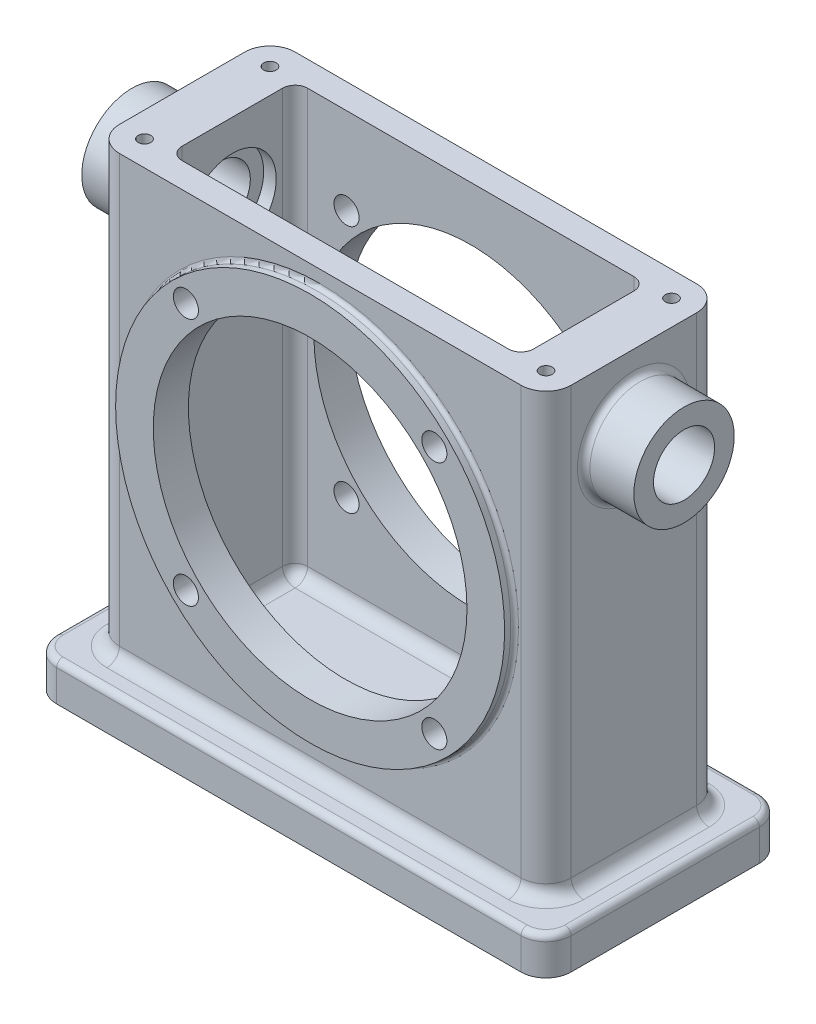
from build123d import *

# Parameters (mm, degrees)
SKETCH1_W           = 130.175
SKETCH1_H           = 60.325
BASE_EXTRUDE_DEPTH  = 9.525
SKETCH2_W           = 114.3
SKETCH2_H           = 44.45
BOSS_EXTRUDE1_DEPTH = 111.125
FILLET1_R           = 6.35
FILLET2_R           = 1.5875
FILLET3_R           = 3.175
CUT_EXTRUDE1_DEPTH  = 107.95
FILLET4_R           = 3.175
SKETCH4_R           = 49.2125
BOSS_EXTRUDE2_DEPTH = 2.54
SKETCH5_R           = 39.6875
CUT_EXTRUDE2_DEPTH  = 55.9275
FILLET5_R           = 0.9906
SKETCH6_R           = 12.7
BOSS_EXTRUDE3_DEPTH = 12.7
SKETCH7_R           = 7.7343
CUT_EXTRUDE3_DEPTH  = 26.4
SKETCH8_R           = 11.1125
CUT_EXTRUDE4_DEPTH  = 3.175
FILLET6_R           = 1.5875
SKETCH9_R           = 3.175
CUT_EXTRUDE5_DEPTH  = 55.9275
CIRPATTERN1_COUNT   = 4
SKETCH10_R          = 1.5875
CUT_EXTRUDE6_DEPTH  = 19.05


with BuildPart() as part:
    # Sketch1 → Base-Extrude (new body)
    with BuildSketch(Plane(origin=(0, 0, 0), x_dir=(1, 0, 0), z_dir=(0, 1, 0))):
        Rectangle(SKETCH1_W, SKETCH1_H)
    extrude(amount=BASE_EXTRUDE_DEPTH)

    # Sketch2 → Boss-Extrude1 (add)
    with BuildSketch(Plane(origin=(0, 9.525, 0), x_dir=(-1, 0, 0), z_dir=(0, 1, 0))):
        Rectangle(SKETCH2_W, SKETCH2_H)
    extrude(amount=BOSS_EXTRUDE1_DEPTH)

    # Fillet1
    fillet1_edges = [part.edges().sort_by_distance(p)[0] for p in [
        (-57.15, 65.0875, -22.225),
        (-57.15, 65.0875, 22.225),
        (57.15, 65.0875, 22.225),
        (57.15, 65.0875, -22.225),
        (-65.0875, 4.7625, -30.1625),
        (65.0875, 4.7625, -30.1625),
        (65.0875, 4.7625, 30.1625),
        (-65.0875, 4.7625, 30.1625),
    ]]
    fillet(fillet1_edges, radius=FILLET1_R)

    # Fillet2
    fillet2_edges = [part.edges().sort_by_distance(p)[0] for p in [
        (0, 9.525, 30.1625),
        (-65.0875, 9.525, 0),
        (65.0875, 9.525, 0),
        (0, 9.525, -30.1625),
        (-63.227628061, 9.525, -28.302628061),
        (63.227628061, 9.525, 28.302628061),
        (63.227628061, 9.525, -28.302628061),
        (-63.227628061, 9.525, 28.302628061),
    ]]
    fillet(fillet2_edges, radius=FILLET2_R)

    # Fillet3
    fillet3_edges = [part.edges().sort_by_distance(p)[0] for p in [
        (-57.15, 9.525, 0),
        (0, 9.525, -22.225),
        (57.15, 9.525, 0),
        (0, 9.525, 22.225),
        (-55.290128061, 9.525, 20.365128061),
        (-55.290128061, 9.525, -20.365128061),
        (55.290128061, 9.525, 20.365128061),
        (55.290128061, 9.525, -20.365128061),
    ]]
    fillet(fillet3_edges, radius=FILLET3_R)

    # Sketch3 → Cut-Extrude1 (cut)
    with BuildSketch(Plane(origin=(0, 120.65, 0), x_dir=(-1, 0, 0), z_dir=(0, 1, 0))):
        with BuildLine():
            Line((41.275, 15.875), (-41.275, 15.875))
            ThreePointArc((-41.275, 15.875), (-43.52006403, 14.94506403), (-44.45, 12.7))
            Line((-44.45, 12.7), (-44.45, -12.7))
            ThreePointArc((-44.45, -12.7), (-43.52006403, -14.94506403), (-41.275, -15.875))
            Line((-41.275, -15.875), (41.275, -15.875))
            ThreePointArc((41.275, -15.875), (43.52006403, -14.94506403), (44.45, -12.7))
            Line((44.45, -12.7), (44.45, 12.7))
            ThreePointArc((44.45, 12.7), (43.52006403, 14.94506403), (41.275, 15.875))
        make_face()
    extrude(amount=-CUT_EXTRUDE1_DEPTH, mode=Mode.SUBTRACT)

    # Fillet4
    fillet4_edges = [part.edges().sort_by_distance(p)[0] for p in [
        (0, 12.7, 15.875),
        (-44.45, 12.7, 0),
        (0, 12.7, -15.875),
        (44.45, 12.7, 0),
    ]]
    fillet(fillet4_edges, radius=FILLET4_R)

    # Sketch4 → Boss-Extrude2 (add)
    with BuildSketch(Plane.XY.offset(22.225)):
        with Locations((0, 67.31)):
            Circle(SKETCH4_R)
    boss_extrude2 = extrude(amount=BOSS_EXTRUDE2_DEPTH)

    # Mirror1: Boss-Extrude2 across plane
    add(boss_extrude2.mirror(Plane.XY))

    # Sketch5 → Cut-Extrude2 (cut, through all)
    with BuildSketch(Plane.XY.offset(24.765)):
        with Locations((0, 67.31)):
            Circle(SKETCH5_R)
    extrude(amount=-CUT_EXTRUDE2_DEPTH, mode=Mode.SUBTRACT)

    # Fillet5
    fillet5_edges = [part.edges().sort_by_distance(p)[0] for p in [
        (-49.2125, 67.31, 22.225),
        (-49.2125, 67.31, -22.225),
    ]]
    fillet(fillet5_edges, radius=FILLET5_R)

    # Sketch6 → Boss-Extrude3 (add)
    with BuildSketch(Plane(origin=(57.15, 0, 0), x_dir=(0, 0, -1), z_dir=(1, 0, 0))):
        with Locations((0, 101.6)):
            Circle(SKETCH6_R)
    boss_extrude3 = extrude(amount=BOSS_EXTRUDE3_DEPTH)

    # Sketch7 → Cut-Extrude3 (cut, through all)
    with BuildSketch(Plane.ZY.offset(-44.45)):
        with Locations((0, 101.6)):
            Circle(SKETCH7_R)
    cut_extrude3 = extrude(amount=-CUT_EXTRUDE3_DEPTH, mode=Mode.SUBTRACT)

    # Sketch8 → Cut-Extrude4 (cut)
    with BuildSketch(Plane.ZY.offset(-44.45)):
        with Locations((0, 101.6)):
            Circle(SKETCH8_R)
    cut_extrude4 = extrude(amount=-CUT_EXTRUDE4_DEPTH, mode=Mode.SUBTRACT)

    # Mirror3: Boss-Extrude3, Cut-Extrude3, Cut-Extrude4 across plane
    add(boss_extrude3.mirror(Plane(origin=(0, 0, 0), x_dir=(0, 0, 1), z_dir=(1, 0, 0))))
    add(cut_extrude3.mirror(Plane(origin=(0, 0, 0), x_dir=(0, 0, 1), z_dir=(1, 0, 0))), mode=Mode.SUBTRACT)
    add(cut_extrude4.mirror(Plane(origin=(0, 0, 0), x_dir=(0, 0, 1), z_dir=(1, 0, 0))), mode=Mode.SUBTRACT)

    # Fillet6
    fillet6_edges = [part.edges().sort_by_distance(p)[0] for p in [
        (57.15, 101.6, 12.7),
        (-57.15, 101.6, 12.7),
    ]]
    fillet(fillet6_edges, radius=FILLET6_R)

    # Sketch9 → Cut-Extrude5 (cut, through all)
    with BuildSketch(Plane.XY.offset(24.765)):
        with Locations((31.430896424, 98.740896424)):
            Circle(SKETCH9_R)
    cut_extrude5 = extrude(amount=-CUT_EXTRUDE5_DEPTH, mode=Mode.SUBTRACT)

    # CirPattern1: Cut-Extrude5 ×4 about axis
    cirpattern1_axis = Axis((0, 67.31, 0), (0, 0, 1))
    for i in range(1, CIRPATTERN1_COUNT):
        add(cut_extrude5.rotate(cirpattern1_axis, i * 360 / CIRPATTERN1_COUNT), mode=Mode.SUBTRACT)

    # Sketch10 → Cut-Extrude6 (cut)
    with BuildSketch(Plane(origin=(0, 120.65, 0), x_dir=(-1, 0, 0), z_dir=(0, 1, 0))):
        with Locations((-50.8, -15.875)):
            Circle(SKETCH10_R)
        with Locations((-50.8, 15.875)):
            Circle(SKETCH10_R)
    cut_extrude6 = extrude(amount=-CUT_EXTRUDE6_DEPTH, mode=Mode.SUBTRACT)

    # Mirror4: Cut-Extrude6 across plane
    add(cut_extrude6.mirror(Plane(origin=(0, 0, 0), x_dir=(0, 0, 1), z_dir=(1, 0, 0))), mode=Mode.SUBTRACT)


solid = part.part
